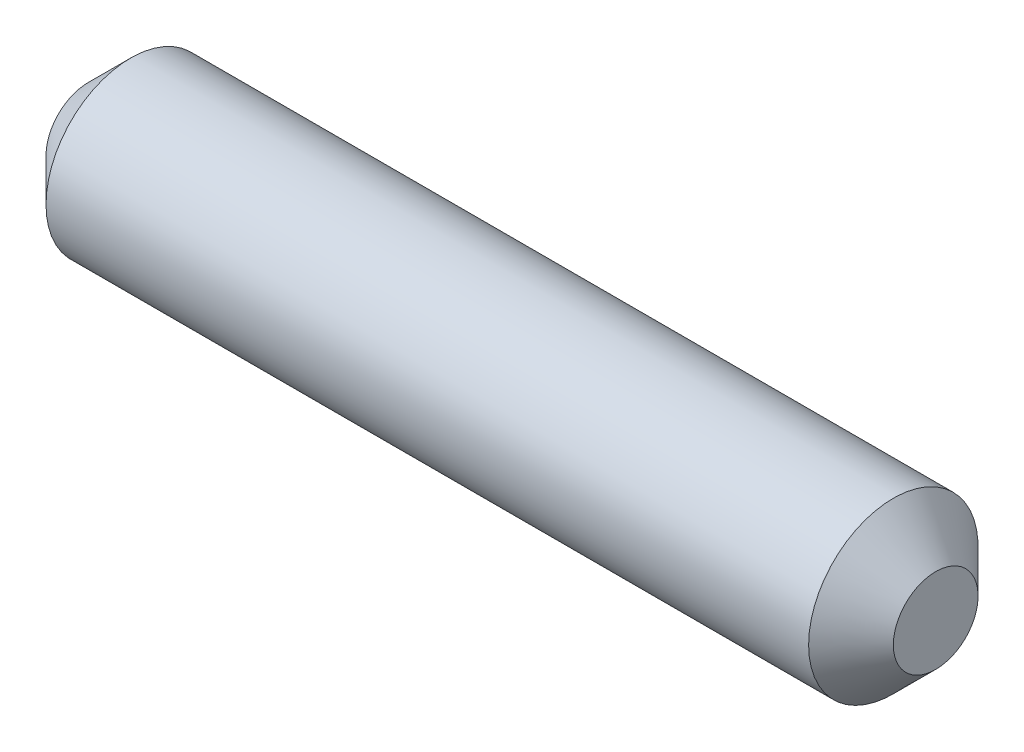
from build123d import *


with BuildPart() as part:
    # Esquisse1 → Révolution1 (revolve)
    with BuildSketch(Plane.XY, mode=Mode.PRIVATE) as r_volution1_sk:
        Polygon((0, 0), (0, 1), (1, 2), (19, 2), (20, 1), (20, 0), align=None)
    revolve(r_volution1_sk.sketch.rotate(Axis((-64.545493934, 0, 0), (1, 0, 0)), 90), axis=Axis((-64.545493934, 0, 0), (1, 0, 0)))  # turned: the seam where the file's is


solid = part.part
